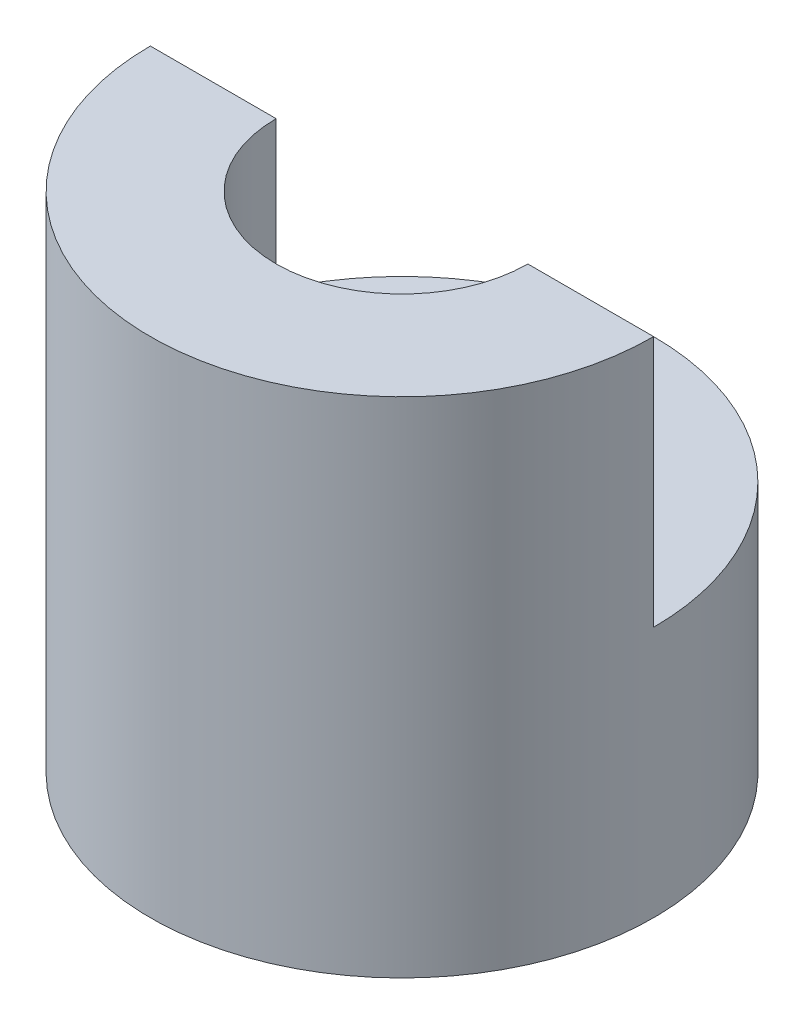
from build123d import *

# Parameters (mm, degrees)
SKETCH1_W          = 10
SKETCH1_H          = 20
SKETCH2_R          = 5
CUT_EXTRUDE1_DEPTH = 20
CUT_EXTRUDE2_DEPTH = 10


with BuildPart() as part:
    # Sketch1 → Revolve1 (revolve)
    with BuildSketch(Plane.XY):
        with Locations((5, 10)):
            Rectangle(SKETCH1_W, SKETCH1_H)
    revolve(axis=Axis((0, 0, 0), (0, 1, 0)))

    # Sketch2 → Cut-Extrude1 (cut)
    with BuildSketch(Plane(origin=(0, 20, 0), x_dir=(1, 0, 0), z_dir=(0, 1, 0))):
        Circle(SKETCH2_R)
    extrude(amount=-CUT_EXTRUDE1_DEPTH, mode=Mode.SUBTRACT)

    # Sketch3 → Cut-Extrude2 (cut)
    with BuildSketch(Plane(origin=(0, 20, 0), x_dir=(1, 0, 0), z_dir=(0, 1, 0))):
        with BuildLine():
            Line((-10, 0), (-5, 0))
            ThreePointArc((-5, 0), (0, 5), (5, 0))
            Line((5, 0), (10, 0))
            ThreePointArc((10, 0), (0, 10), (-10, 0))
        make_face()
    extrude(amount=-CUT_EXTRUDE2_DEPTH, mode=Mode.SUBTRACT)


solid = part.part
